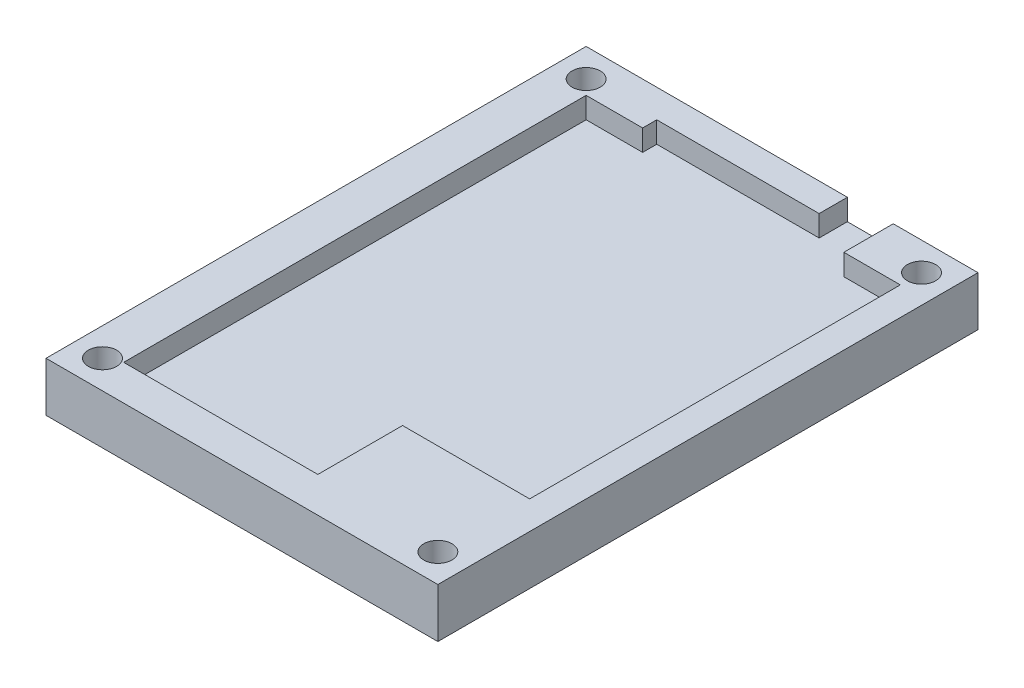
from build123d import *

# Parameters (mm, degrees)
SKETCH1_W                    = 55.5
SKETCH1_H                    = 76.5
BOSS_EXTRUDE1_DEPTH          = 4
BOSS_EXTRUDE2_DEPTH          = 3
F_4_0_4_DIAMETER_HOLE1_D     = 4
F_4_0_4_DIAMETER_HOLE1_DEPTH = 7


with BuildPart() as part:
    # Sketch1 → Boss-Extrude1 (new body)
    with BuildSketch(Plane(origin=(0, 0, 0), x_dir=(1, 0, 0), z_dir=(0, 1, 0))):
        with Locations((6.260396975, -11.980623819)):
            Rectangle(SKETCH1_W, SKETCH1_H)
    extrude(amount=BOSS_EXTRUDE1_DEPTH)

    # Sketch2 → Boss-Extrude2 (add)
    with BuildSketch(Plane(origin=(0, 4, 0), x_dir=(1, 0, 0), z_dir=(0, 1, 0))):
        Polygon((-21.489603025, 26.269376181), (-21.489603025, -50.230623819), (34.010396975, -50.230623819), (34.010396975, 26.269376181), (22.010396975, 26.269376181), (22.010396975, 19.269376181), (30.010396975, 19.269376181), (30.010396975, -33.230623819), (12.010396975, -33.230623819), (12.010396975, -45.230623819), (-15.489603025, -45.230623819), (-15.489603025, 20.269376181), (-7.489603025, 20.269376181), (-7.489603025, 22.269376181), (15.510396975, 22.269376181), (15.510396975, 26.269376181), align=None)
    extrude(amount=BOSS_EXTRUDE2_DEPTH)

    # Ø4.0 (4) Diameter Hole1
    with Locations(Plane(origin=(0, 7, 0), x_dir=(1, 0, 0), z_dir=(0, 1, 0))):
        with Locations((30.010396975, 22.269376181), (30.010396975, -46.230623819), (-17.489603025, -46.230623819), (-17.489603025, 22.269376181)):
            Hole(F_4_0_4_DIAMETER_HOLE1_D / 2, depth=F_4_0_4_DIAMETER_HOLE1_DEPTH)


solid = part.part
